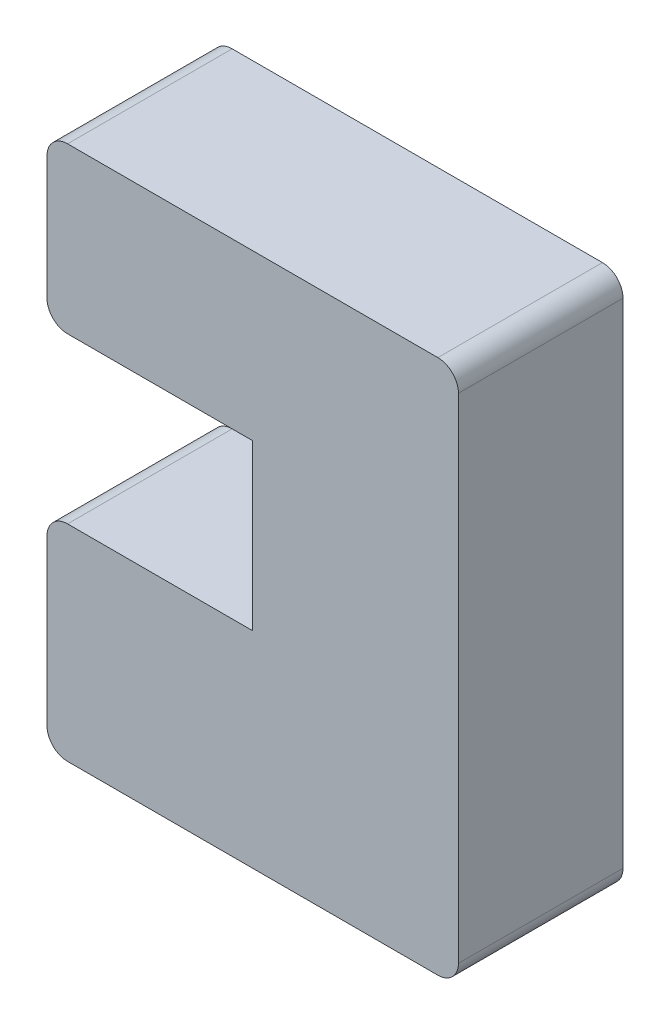
from build123d import *

# Parameters (mm, degrees)
BOSS_EXTRUDE1_DEPTH = 8


with BuildPart() as part:
    # Sketch1 → Boss-Extrude1 (new body)
    with BuildSketch(Plane.XY):
        with BuildLine():
            Line((1, 0), (19, 0))
            ThreePointArc((19, 0), (19.707106781, 0.292893219), (20, 1))
            Line((20, 1), (20, 25))
            ThreePointArc((20, 25), (19.707106781, 25.707106781), (19, 26))
            Line((19, 26), (1, 26))
            ThreePointArc((1, 26), (0.292893219, 25.707106781), (0, 25))
            Line((0, 25), (0, 19))
            ThreePointArc((0, 19), (0.292893219, 18.292893219), (1, 18))
            Line((1, 18), (10, 18))
            Line((10, 18), (10, 10))
            Line((10, 10), (1, 10))
            ThreePointArc((1, 10), (0.292893219, 9.707106781), (0, 9))
            Line((0, 9), (0, 1))
            ThreePointArc((0, 1), (0.292893219, 0.292893219), (1, 0))
        make_face()
    extrude(amount=BOSS_EXTRUDE1_DEPTH)


solid = part.part
